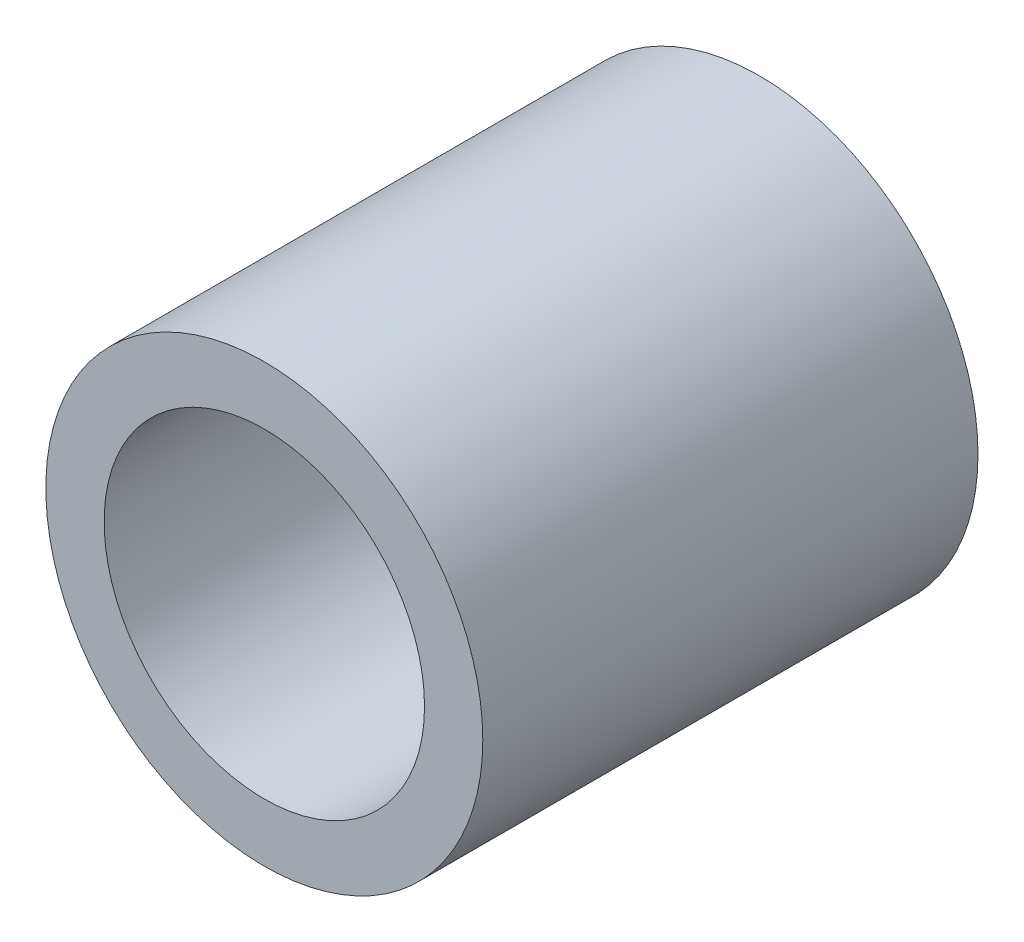
from build123d import *

# Parameters (mm, degrees)
SKETCH1_R           = 15.24
SKETCH1_R_2         = 11.176
BOSS_EXTRUDE1_DEPTH = 34.544


with BuildPart() as part:
    # Sketch1 → Boss-Extrude1 (new body)
    with BuildSketch(Plane.XY):
        Circle(SKETCH1_R)
        Circle(SKETCH1_R_2, mode=Mode.SUBTRACT)
    extrude(amount=BOSS_EXTRUDE1_DEPTH)


solid = part.part
